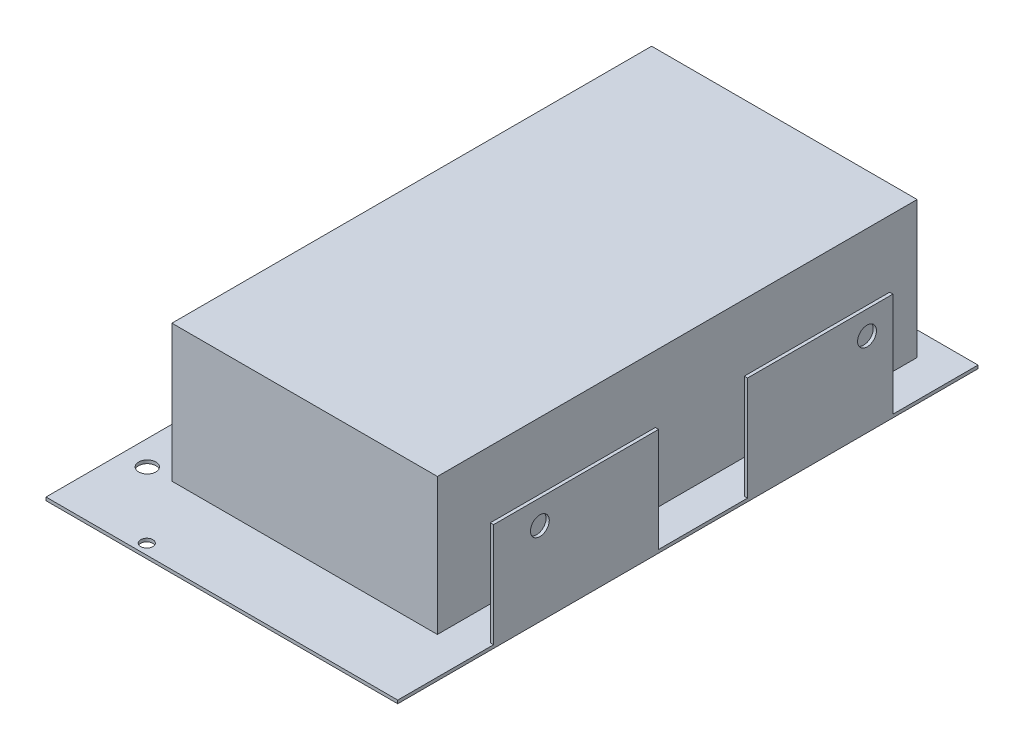
from build123d import *

# Parameters (mm, degrees)
SKETCH1_W        = 128.5
SKETCH1_H        = 212
SKETCH1_R        = 3.15
SKETCH1_R_2      = 2.215
BASE_DEPTH       = 1.18
SKETCH4_W        = 97
SKETCH4_H        = 175.26
CAPACITORS_DEPTH = 50
SKETCH2_W        = 1.18
SKETCH2_H        = 60.3
SKETCH2_H_2      = 53.1
TABS_DEPTH       = 38
TAB_HOLES_REACH  = 130.5
SKETCH3_R        = 3.44
SKETCH3_R_2      = 3.45


with BuildPart() as part:
    # Sketch1 → Base (new body)
    with BuildSketch(Plane(origin=(0, 0, 0), x_dir=(1, 0, 0), z_dir=(0, 1, 0))):
        Rectangle(SKETCH1_W, SKETCH1_H)
        with Locations((-55.25, -78)):
            Circle(SKETCH1_R, mode=Mode.SUBTRACT)
        with Locations((-31.25, -102.185)):
            Circle(SKETCH1_R_2, mode=Mode.SUBTRACT)
    extrude(amount=BASE_DEPTH)

    # Sketch4 → Capacitors (add)
    with BuildSketch(Plane(origin=(0, 1.18, 0), x_dir=(1, 0, 0), z_dir=(0, 1, 0))):
        with Locations((2.25, 9.63)):
            Rectangle(SKETCH4_W, SKETCH4_H)
    extrude(amount=CAPACITORS_DEPTH)

    # Sketch2 → Tabs (add)
    with BuildSketch(Plane(origin=(0, 1.18, 0), x_dir=(1, 0, 0), z_dir=(0, 1, 0))):
        with Locations((63.66, -40.85)):
            Rectangle(SKETCH2_W, SKETCH2_H)
        with Locations((63.66, 48.35)):
            Rectangle(SKETCH2_W, SKETCH2_H_2)
    extrude(amount=TABS_DEPTH)

    # Sketch3 → Tab Holes (cut, up to next)
    with BuildSketch(Plane(origin=(64.25, 0, 0), x_dir=(0, 0, -1), z_dir=(1, 0, 0)), mode=Mode.PRIVATE) as tab_holes_sk1:
        with Locations((-54.07, 30.38)):
            Circle(SKETCH3_R)
    tab_holes_tool1 = extrude(tab_holes_sk1.sketch, amount=-TAB_HOLES_REACH, mode=Mode.PRIVATE) & part.part
    add(tab_holes_tool1.solids().sort_by_distance((64.25, 30.38, 54.07))[0], mode=Mode.SUBTRACT)
    # Sketch3 → Tab Holes (cut, up to next)
    with BuildSketch(Plane(origin=(64.25, 0, 0), x_dir=(0, 0, -1), z_dir=(1, 0, 0)), mode=Mode.PRIVATE) as tab_holes_sk2:
        with Locations((65.46, 30.64)):
            Circle(SKETCH3_R_2)
    tab_holes_tool2 = extrude(tab_holes_sk2.sketch, amount=-TAB_HOLES_REACH, mode=Mode.PRIVATE) & part.part
    add(tab_holes_tool2.solids().sort_by_distance((64.25, 30.64, -65.46))[0], mode=Mode.SUBTRACT)


solid = part.part
